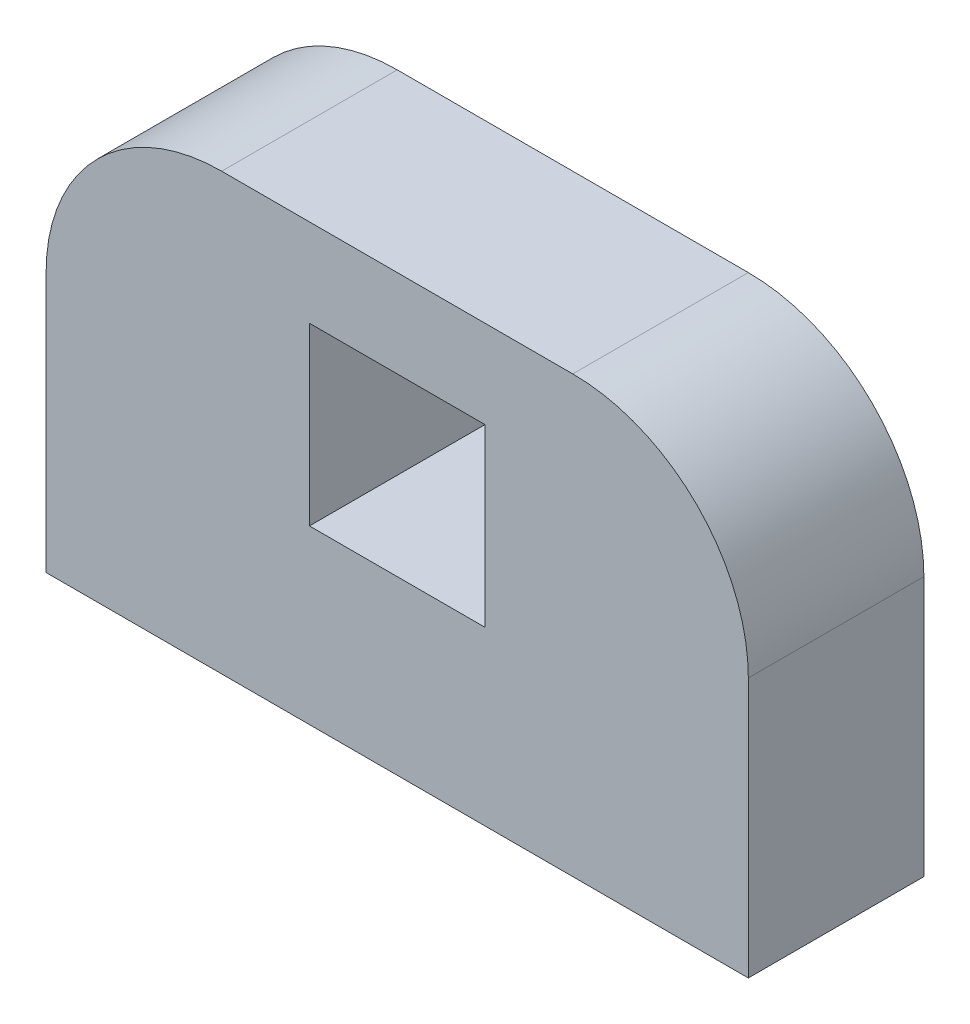
from build123d import *

# Parameters (mm, degrees)
SKETCH1_W           = 3.175
SKETCH1_H           = 3.175
BOSS_EXTRUDE1_DEPTH = 3.175


with BuildPart() as part:
    # Sketch1 → Boss-Extrude1 (new body)
    with BuildSketch(Plane.XY):
        with BuildLine():
            Line((0, 0), (12.7, 0))
            Line((12.7, 0), (12.7, 4.699))
            ThreePointArc((12.7, 4.699), (11.77006403, 6.94406403), (9.525, 7.874))
            Line((9.525, 7.874), (3.175, 7.874))
            ThreePointArc((3.175, 7.874), (0.92993597, 6.94406403), (0, 4.699))
            Line((0, 4.699), (0, 0))
        make_face()
        with Locations((6.35, 4.699)):
            Rectangle(SKETCH1_W, SKETCH1_H, mode=Mode.SUBTRACT)
    extrude(amount=BOSS_EXTRUDE1_DEPTH)


solid = part.part
